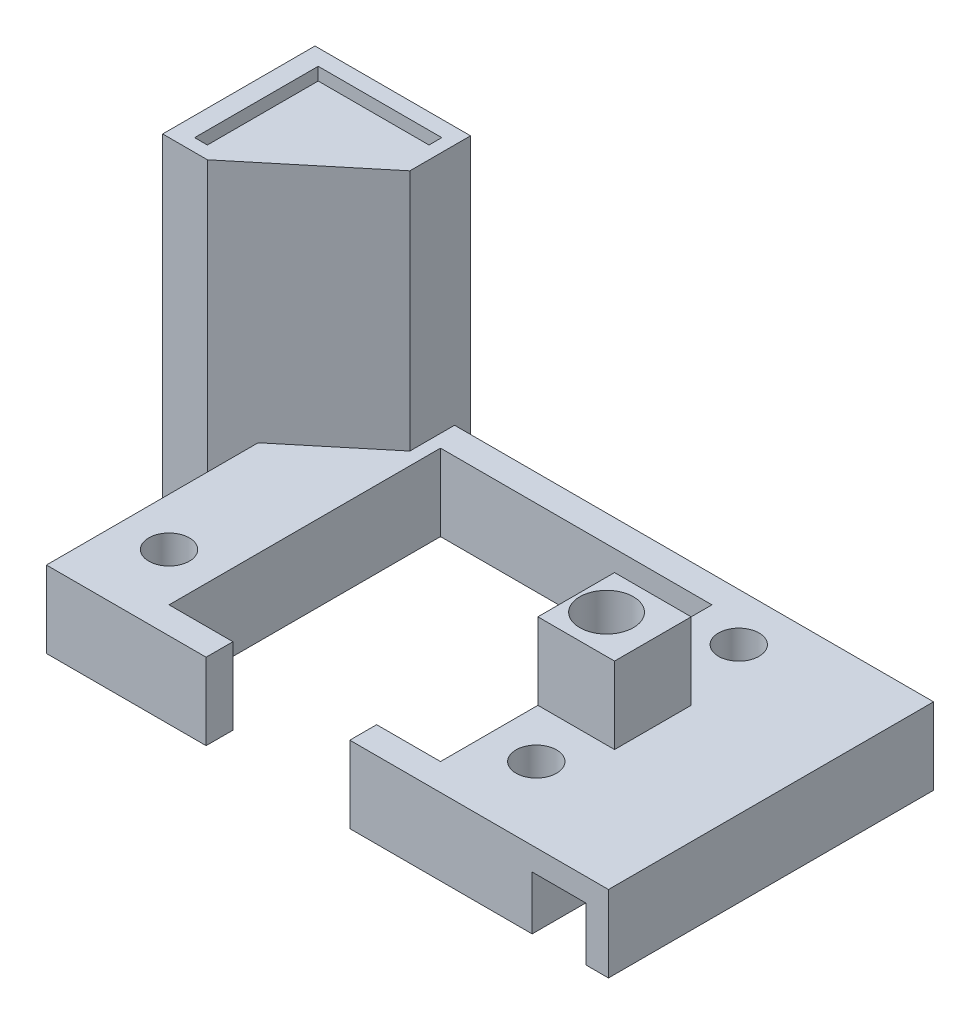
from build123d import *

# Parameters (mm, degrees)
SKETCH1_R           = 3.175
BOSS_EXTRUDE1_DEPTH = 12
BOSS_EXTRUDE2_DEPTH = 50.9
SKETCH5_W           = 12
SKETCH5_H           = 12
SKETCH5_R           = 4.2
BOSS_EXTRUDE3_DEPTH = 12
BOSS_EXTRUDE8_DEPTH = 50


with BuildPart() as part:
    # Sketch1 → Boss-Extrude1 (new body)
    with BuildSketch(Plane(origin=(0, 0, 0), x_dir=(1, 0, 0), z_dir=(0, 1, 0))):
        Polygon((-15, 0), (0, 0), (0, 42.5), (42.5, 42.5), (42.5, 0), (57.5, 0), (57.5, 46.7), (-15, 46.7), align=None)
        with Locations((-7.5, 7.5)):
            Circle(SKETCH1_R, mode=Mode.SUBTRACT)
        with Locations((50, 7.5)):
            Circle(SKETCH1_R, mode=Mode.SUBTRACT)
        with Locations((50, 39.2)):
            Circle(SKETCH1_R, mode=Mode.SUBTRACT)
        Polygon((10, 0), (0, 0), (-15, 0), (-15, -4.2), (10, -4.2), align=None)
        Polygon((42.5, 0), (32.5, 0), (32.5, -4.2), (57.5, -4.2), (57.5, 0), align=None)
    extrude(amount=BOSS_EXTRUDE1_DEPTH)

    # Sketch4 → Boss-Extrude2 (add)
    with BuildSketch(Plane(origin=(53.3, 0, 4.2), x_dir=(-1, 0, 0), z_dir=(0, 0, -1))):
        Polygon((-19.7, 12), (-19.7, 0), (-16.15, 0), (-16.15, 8.4), (-7.75, 8.4), (-7.75, 0), (-4.2, 0), (-4.2, 12), align=None)
    extrude(amount=BOSS_EXTRUDE2_DEPTH)

    # Sketch5 → Boss-Extrude3 (add)
    with BuildSketch(Plane(origin=(0, 12, 0), x_dir=(1, 0, 0), z_dir=(0, 1, 0))):
        with Locations((48.5, 21.25)):
            Rectangle(SKETCH5_W, SKETCH5_H)
        with Locations((47.25, 21.25)):
            Circle(SKETCH5_R, mode=Mode.SUBTRACT)
    extrude(amount=BOSS_EXTRUDE3_DEPTH)

    # Sketch6 → Boss-Extrude8 (add)
    with BuildSketch(Plane.XZ):
        Polygon((-2, -39.7), (-15, -28.947838617), (-15, -44.7), (-4, -44.7), (-4, -46.7), (-2, -46.7), align=None)
        Polygon((-15, -28.947838617), (-19.35, -25.35), (-26.35, -25.35), (-26.35, -46.7), (-23.35, -46.7), (-23.35, -27.35), (-21.35, -27.35), (-21.35, -44.7), (-15, -44.7), align=None)
        Polygon((-23.35, -46.7), (-26.35, -46.7), (-26.35, -49.2), (-2, -49.2), (-2, -46.7), (-4, -46.7), (-15, -46.7), align=None)
    extrude(amount=-BOSS_EXTRUDE8_DEPTH)


solid = part.part
